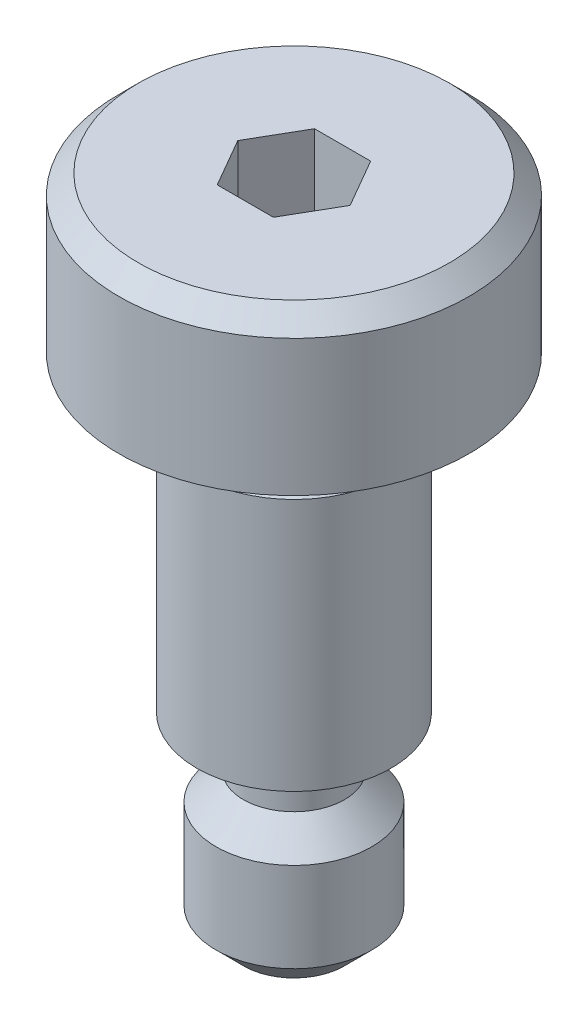
from build123d import *

# Parameters (mm, degrees)
CUT_EXTRUDE1_DEPTH = 3


with BuildPart() as part:
    # Sketch1 → Revolve1 (revolve)
    with BuildSketch(Plane.XY):
        with BuildLine():
            Line((0, 0), (0, 17))
            Line((0, 17), (4, 17))
            Line((4, 17), (4.5, 16.5))
            Line((4.5, 16.5), (4.5, 13))
            Line((4.5, 13), (2.5, 13))
            ThreePointArc((2.5, 13), (2.146446609, 12.853553391), (2, 12.5))
            Line((2, 12.5), (2, 12))
            Line((2, 12), (2.5, 11.5))
            Line((2.5, 11.5), (2.5, 5))
            Line((2.5, 5), (2, 5))
            ThreePointArc((2, 5), (1.505025253, 4.794974747), (1.3, 4.3))
            Line((1.3, 4.3), (1.3, 3.7))
            Line((1.3, 3.7), (2, 3))
            Line((2, 3), (2, 0.7))
            Line((2, 0.7), (1.3, 0))
            Line((1.3, 0), (0, 0))
        make_face()
    revolve(axis=Axis((0, 0, 0), (0, 1, 0)))

    # Sketch2 → Cut-Extrude1 (cut)
    with BuildSketch(Plane(origin=(0, 17, 0), x_dir=(1, 0, 0), z_dir=(0, 1, 0))):
        Polygon((0.721687836, 1.25), (-0.721687836, 1.25), (-1.443375673, 0), (-0.721687836, -1.25), (0.721687836, -1.25), (1.443375673, 0), align=None)
    extrude(amount=-CUT_EXTRUDE1_DEPTH, mode=Mode.SUBTRACT)


solid = part.part
